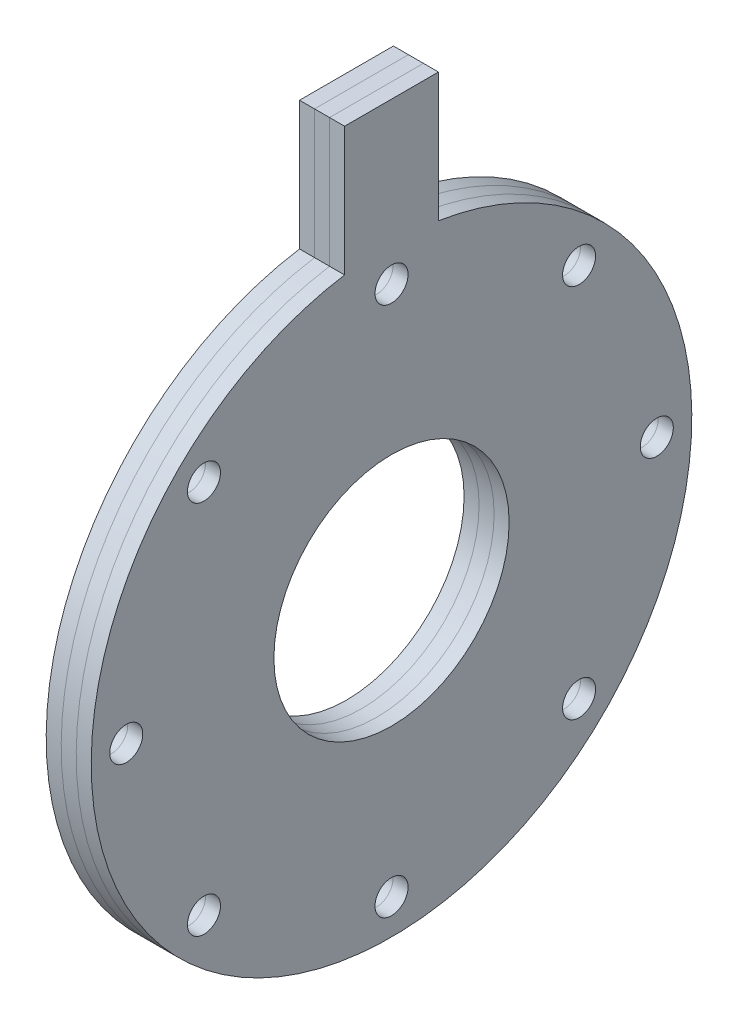
from build123d import *

# Parameters (mm, degrees)
SKETCH1_R                                    = 60
BOSS_EXTRUDE1_DEPTH                          = 1.5
BOSS_EXTRUDE2_DEPTH                          = 1.5
BOSS_EXTRUDE3_DEPTH                          = 3
BOSS_EXTRUDE4_DEPTH                          = 3
CSK_FOR_M6_COUNTERSUNK_FLAT_HEAD_SCR_2_COUNT = 2
CSK_FOR_M6_COUNTERSUNK_FLAT_HEAD_SCR_2_PITCH = 40.564443831
CSK_FOR_M6_COUNTERSUNK_FLAT_HEAD_SCR_3_COUNT = 2
CSK_FOR_M6_COUNTERSUNK_FLAT_HEAD_SCR_3_PITCH = 74.953318806
CSK_FOR_M6_COUNTERSUNK_FLAT_HEAD_SCR_4_COUNT = 2
CSK_FOR_M6_COUNTERSUNK_FLAT_HEAD_SCR_4_PITCH = 97.931230446
CSK_FOR_M6_COUNTERSUNK_FLAT_HEAD_SCR_5_COUNT = 2
CSK_FOR_M6_COUNTERSUNK_FLAT_HEAD_SCR_5_PITCH = 106
CSK_FOR_M6_COUNTERSUNK_FLAT_HEAD_SCR_6_COUNT = 2
CSK_FOR_M6_COUNTERSUNK_FLAT_HEAD_SCR_6_PITCH = 97.931230446
CSK_FOR_M6_COUNTERSUNK_FLAT_HEAD_SCR_7_COUNT = 2
CSK_FOR_M6_COUNTERSUNK_FLAT_HEAD_SCR_7_PITCH = 74.953318806
CSK_FOR_M6_COUNTERSUNK_FLAT_HEAD_SCR_8_COUNT = 2
CSK_FOR_M6_COUNTERSUNK_FLAT_HEAD_SCR_8_PITCH = 40.564443831
SKETCH8_R                                    = 23.5
CUT_EXTRUDE1_DEPTH                           = 10


with BuildPart() as part:
    # Sketch1 → Boss-Extrude1 (new body, symmetric)
    with BuildSketch(Plane(origin=(0, 0, 0), x_dir=(0, 0, -1), z_dir=(1, 0, 0))):
        Circle(SKETCH1_R)
    extrude(amount=BOSS_EXTRUDE1_DEPTH, both=True)

    # Sketch3 → Boss-Extrude2 (add, symmetric)
    with BuildSketch(Plane(origin=(0, 0, 0), x_dir=(0, 0, -1), z_dir=(1, 0, 0))):
        with BuildLine():
            Line((-9.379163336, 85), (-9.379163336, 59.262393599))
            ThreePointArc((-9.379163336, 59.262393599), (0, 60), (9.379163336, 59.262393599))
            Line((9.379163336, 59.262393599), (9.379163336, 85))
            Line((9.379163336, 85), (-9.379163336, 85))
        make_face()
    extrude(amount=BOSS_EXTRUDE2_DEPTH, both=True)


with BuildPart() as body_2:
    # Sketch6 → Boss-Extrude3 (new body)
    with BuildSketch(Plane(origin=(1.5, 0, 0), x_dir=(0, 0, -1), z_dir=(1, 0, 0))):
        with BuildLine():
            Line((9.379163336, 59.262393599), (9.379163336, 85))
            Line((9.379163336, 85), (-9.379163336, 85))
            Line((-9.379163336, 85), (-9.379163336, 59.262393599))
            ThreePointArc((-9.379163336, 59.262393599), (0, -60), (9.379163336, 59.262393599))
        make_face()
    extrude(amount=BOSS_EXTRUDE3_DEPTH)


with BuildPart() as body_3:
    # Sketch7 → Boss-Extrude4 (new body)
    with BuildSketch(Plane(origin=(4.5, 0, 0), x_dir=(0, 0, -1), z_dir=(1, 0, 0))):
        with BuildLine():
            Line((9.379163336, 59.262393599), (9.379163336, 85))
            Line((9.379163336, 85), (-9.379163336, 85))
            Line((-9.379163336, 85), (-9.379163336, 59.262393599))
            ThreePointArc((-9.379163336, 59.262393599), (0, -60), (9.379163336, 59.262393599))
        make_face()
    extrude(amount=BOSS_EXTRUDE4_DEPTH)


with BuildPart() as csk_for_m6_countersunk_flat_head_screw1_tool:
    # Sketch5 → CSK for M6 Countersunk Flat Head Screw1 (revolve)
    with BuildSketch(Plane(origin=(-1.5, 37.476659403, 37.476659403), x_dir=(0, 0, 1), z_dir=(0, 1, 0))):
        Polygon((0, 0), (0, 9), (3.3, 9), (3.3, 3), (6.3, 0), align=None)
    csk_for_m6_countersunk_flat_head_screw1 = revolve(axis=Axis((-7.85, 37.476659403, 37.476659403), (1, 0, 0)))


with BuildPart() as part_1:
    add(part.part)

    # CSK for M6 Countersunk Flat Head Screw1: cut by csk_for_m6_countersunk_flat_head_screw1_tool
    add(csk_for_m6_countersunk_flat_head_screw1_tool.part, mode=Mode.SUBTRACT)


with BuildPart() as body_2_1:
    add(body_2.part)

    # CSK for M6 Countersunk Flat Head Screw1: cut by csk_for_m6_countersunk_flat_head_screw1_tool
    add(csk_for_m6_countersunk_flat_head_screw1_tool.part, mode=Mode.SUBTRACT)


with BuildPart() as body_3_1:
    add(body_3.part)

    # CSK for M6 Countersunk Flat Head Screw1: cut by csk_for_m6_countersunk_flat_head_screw1_tool
    add(csk_for_m6_countersunk_flat_head_screw1_tool.part, mode=Mode.SUBTRACT)


with BuildPart() as csk_for_m6_countersunk_flat_head_scr_2_tool:
    # CSK for M6 Countersunk Flat Head Scr 2: CSK for M6 Countersunk Flat Head Screw1 ×2
    with Locations(*[Vector(0, -0.923879533, 0.382683432) * (i * CSK_FOR_M6_COUNTERSUNK_FLAT_HEAD_SCR_2_PITCH) for i in range(1, CSK_FOR_M6_COUNTERSUNK_FLAT_HEAD_SCR_2_COUNT)]):
        add(csk_for_m6_countersunk_flat_head_screw1)


with BuildPart() as part_2:
    add(part_1.part)

    # CSK for M6 Countersunk Flat Head Scr 2: cut by csk_for_m6_countersunk_flat_head_scr_2_tool
    add(csk_for_m6_countersunk_flat_head_scr_2_tool.part, mode=Mode.SUBTRACT)


with BuildPart() as body_2_2:
    add(body_2_1.part)

    # CSK for M6 Countersunk Flat Head Scr 2: cut by csk_for_m6_countersunk_flat_head_scr_2_tool
    add(csk_for_m6_countersunk_flat_head_scr_2_tool.part, mode=Mode.SUBTRACT)


with BuildPart() as body_3_2:
    add(body_3_1.part)

    # CSK for M6 Countersunk Flat Head Scr 2: cut by csk_for_m6_countersunk_flat_head_scr_2_tool
    add(csk_for_m6_countersunk_flat_head_scr_2_tool.part, mode=Mode.SUBTRACT)


with BuildPart() as csk_for_m6_countersunk_flat_head_scr_3_tool:
    # CSK for M6 Countersunk Flat Head Scr 3: CSK for M6 Countersunk Flat Head Screw1 ×2
    with Locations(*[(0, -i * CSK_FOR_M6_COUNTERSUNK_FLAT_HEAD_SCR_3_PITCH, 0) for i in range(1, CSK_FOR_M6_COUNTERSUNK_FLAT_HEAD_SCR_3_COUNT)]):
        add(csk_for_m6_countersunk_flat_head_screw1)


with BuildPart() as part_3:
    add(part_2.part)

    # CSK for M6 Countersunk Flat Head Scr 3: cut by csk_for_m6_countersunk_flat_head_scr_3_tool
    add(csk_for_m6_countersunk_flat_head_scr_3_tool.part, mode=Mode.SUBTRACT)


with BuildPart() as body_2_3:
    add(body_2_2.part)

    # CSK for M6 Countersunk Flat Head Scr 3: cut by csk_for_m6_countersunk_flat_head_scr_3_tool
    add(csk_for_m6_countersunk_flat_head_scr_3_tool.part, mode=Mode.SUBTRACT)


with BuildPart() as body_3_3:
    add(body_3_2.part)

    # CSK for M6 Countersunk Flat Head Scr 3: cut by csk_for_m6_countersunk_flat_head_scr_3_tool
    add(csk_for_m6_countersunk_flat_head_scr_3_tool.part, mode=Mode.SUBTRACT)


with BuildPart() as csk_for_m6_countersunk_flat_head_scr_4_tool:
    # CSK for M6 Countersunk Flat Head Scr 4: CSK for M6 Countersunk Flat Head Screw1 ×2
    with Locations(*[Vector(0, -0.923879533, -0.382683432) * (i * CSK_FOR_M6_COUNTERSUNK_FLAT_HEAD_SCR_4_PITCH) for i in range(1, CSK_FOR_M6_COUNTERSUNK_FLAT_HEAD_SCR_4_COUNT)]):
        add(csk_for_m6_countersunk_flat_head_screw1)


with BuildPart() as part_4:
    add(part_3.part)

    # CSK for M6 Countersunk Flat Head Scr 4: cut by csk_for_m6_countersunk_flat_head_scr_4_tool
    add(csk_for_m6_countersunk_flat_head_scr_4_tool.part, mode=Mode.SUBTRACT)


with BuildPart() as body_2_4:
    add(body_2_3.part)

    # CSK for M6 Countersunk Flat Head Scr 4: cut by csk_for_m6_countersunk_flat_head_scr_4_tool
    add(csk_for_m6_countersunk_flat_head_scr_4_tool.part, mode=Mode.SUBTRACT)


with BuildPart() as body_3_4:
    add(body_3_3.part)

    # CSK for M6 Countersunk Flat Head Scr 4: cut by csk_for_m6_countersunk_flat_head_scr_4_tool
    add(csk_for_m6_countersunk_flat_head_scr_4_tool.part, mode=Mode.SUBTRACT)


with BuildPart() as csk_for_m6_countersunk_flat_head_scr_5_tool:
    # CSK for M6 Countersunk Flat Head Scr 5: CSK for M6 Countersunk Flat Head Screw1 ×2
    with Locations(*[Vector(0, -0.707106781, -0.707106781) * (i * CSK_FOR_M6_COUNTERSUNK_FLAT_HEAD_SCR_5_PITCH) for i in range(1, CSK_FOR_M6_COUNTERSUNK_FLAT_HEAD_SCR_5_COUNT)]):
        add(csk_for_m6_countersunk_flat_head_screw1)


with BuildPart() as part_5:
    add(part_4.part)

    # CSK for M6 Countersunk Flat Head Scr 5: cut by csk_for_m6_countersunk_flat_head_scr_5_tool
    add(csk_for_m6_countersunk_flat_head_scr_5_tool.part, mode=Mode.SUBTRACT)


with BuildPart() as body_2_5:
    add(body_2_4.part)

    # CSK for M6 Countersunk Flat Head Scr 5: cut by csk_for_m6_countersunk_flat_head_scr_5_tool
    add(csk_for_m6_countersunk_flat_head_scr_5_tool.part, mode=Mode.SUBTRACT)


with BuildPart() as body_3_5:
    add(body_3_4.part)

    # CSK for M6 Countersunk Flat Head Scr 5: cut by csk_for_m6_countersunk_flat_head_scr_5_tool
    add(csk_for_m6_countersunk_flat_head_scr_5_tool.part, mode=Mode.SUBTRACT)


with BuildPart() as csk_for_m6_countersunk_flat_head_scr_6_tool:
    # CSK for M6 Countersunk Flat Head Scr 6: CSK for M6 Countersunk Flat Head Screw1 ×2
    with Locations(*[Vector(0, -0.382683432, -0.923879533) * (i * CSK_FOR_M6_COUNTERSUNK_FLAT_HEAD_SCR_6_PITCH) for i in range(1, CSK_FOR_M6_COUNTERSUNK_FLAT_HEAD_SCR_6_COUNT)]):
        add(csk_for_m6_countersunk_flat_head_screw1)


with BuildPart() as part_6:
    add(part_5.part)

    # CSK for M6 Countersunk Flat Head Scr 6: cut by csk_for_m6_countersunk_flat_head_scr_6_tool
    add(csk_for_m6_countersunk_flat_head_scr_6_tool.part, mode=Mode.SUBTRACT)


with BuildPart() as body_2_6:
    add(body_2_5.part)

    # CSK for M6 Countersunk Flat Head Scr 6: cut by csk_for_m6_countersunk_flat_head_scr_6_tool
    add(csk_for_m6_countersunk_flat_head_scr_6_tool.part, mode=Mode.SUBTRACT)


with BuildPart() as body_3_6:
    add(body_3_5.part)

    # CSK for M6 Countersunk Flat Head Scr 6: cut by csk_for_m6_countersunk_flat_head_scr_6_tool
    add(csk_for_m6_countersunk_flat_head_scr_6_tool.part, mode=Mode.SUBTRACT)


with BuildPart() as csk_for_m6_countersunk_flat_head_scr_7_tool:
    # CSK for M6 Countersunk Flat Head Scr 7: CSK for M6 Countersunk Flat Head Screw1 ×2
    with Locations(*[(0, 0, -i * CSK_FOR_M6_COUNTERSUNK_FLAT_HEAD_SCR_7_PITCH) for i in range(1, CSK_FOR_M6_COUNTERSUNK_FLAT_HEAD_SCR_7_COUNT)]):
        add(csk_for_m6_countersunk_flat_head_screw1)


with BuildPart() as part_7:
    add(part_6.part)

    # CSK for M6 Countersunk Flat Head Scr 7: cut by csk_for_m6_countersunk_flat_head_scr_7_tool
    add(csk_for_m6_countersunk_flat_head_scr_7_tool.part, mode=Mode.SUBTRACT)


with BuildPart() as body_2_7:
    add(body_2_6.part)

    # CSK for M6 Countersunk Flat Head Scr 7: cut by csk_for_m6_countersunk_flat_head_scr_7_tool
    add(csk_for_m6_countersunk_flat_head_scr_7_tool.part, mode=Mode.SUBTRACT)


with BuildPart() as body_3_7:
    add(body_3_6.part)

    # CSK for M6 Countersunk Flat Head Scr 7: cut by csk_for_m6_countersunk_flat_head_scr_7_tool
    add(csk_for_m6_countersunk_flat_head_scr_7_tool.part, mode=Mode.SUBTRACT)


with BuildPart() as csk_for_m6_countersunk_flat_head_scr_8_tool:
    # CSK for M6 Countersunk Flat Head Scr 8: CSK for M6 Countersunk Flat Head Screw1 ×2
    with Locations(*[Vector(0, 0.382683432, -0.923879533) * (i * CSK_FOR_M6_COUNTERSUNK_FLAT_HEAD_SCR_8_PITCH) for i in range(1, CSK_FOR_M6_COUNTERSUNK_FLAT_HEAD_SCR_8_COUNT)]):
        add(csk_for_m6_countersunk_flat_head_screw1)


with BuildPart() as part_8:
    add(part_7.part)

    # CSK for M6 Countersunk Flat Head Scr 8: cut by csk_for_m6_countersunk_flat_head_scr_8_tool
    add(csk_for_m6_countersunk_flat_head_scr_8_tool.part, mode=Mode.SUBTRACT)


with BuildPart() as body_2_8:
    add(body_2_7.part)

    # CSK for M6 Countersunk Flat Head Scr 8: cut by csk_for_m6_countersunk_flat_head_scr_8_tool
    add(csk_for_m6_countersunk_flat_head_scr_8_tool.part, mode=Mode.SUBTRACT)


with BuildPart() as body_3_8:
    add(body_3_7.part)

    # CSK for M6 Countersunk Flat Head Scr 8: cut by csk_for_m6_countersunk_flat_head_scr_8_tool
    add(csk_for_m6_countersunk_flat_head_scr_8_tool.part, mode=Mode.SUBTRACT)


with BuildPart() as cut_extrude1_tool:
    # Sketch8 → Cut-Extrude1 (new body, through all)
    with BuildSketch(Plane.ZY.offset(1.5)):
        Circle(SKETCH8_R)
    extrude(amount=-CUT_EXTRUDE1_DEPTH)


with BuildPart() as part_9:
    add(part_8.part)

    # Cut-Extrude1: cut by cut_extrude1_tool
    add(cut_extrude1_tool.part, mode=Mode.SUBTRACT)


with BuildPart() as body_2_9:
    add(body_2_8.part)

    # Cut-Extrude1: cut by cut_extrude1_tool
    add(cut_extrude1_tool.part, mode=Mode.SUBTRACT)


with BuildPart() as body_3_9:
    add(body_3_8.part)

    # Cut-Extrude1: cut by cut_extrude1_tool
    add(cut_extrude1_tool.part, mode=Mode.SUBTRACT)


solid = Compound([part_9.part, body_2_9.part, body_3_9.part])
